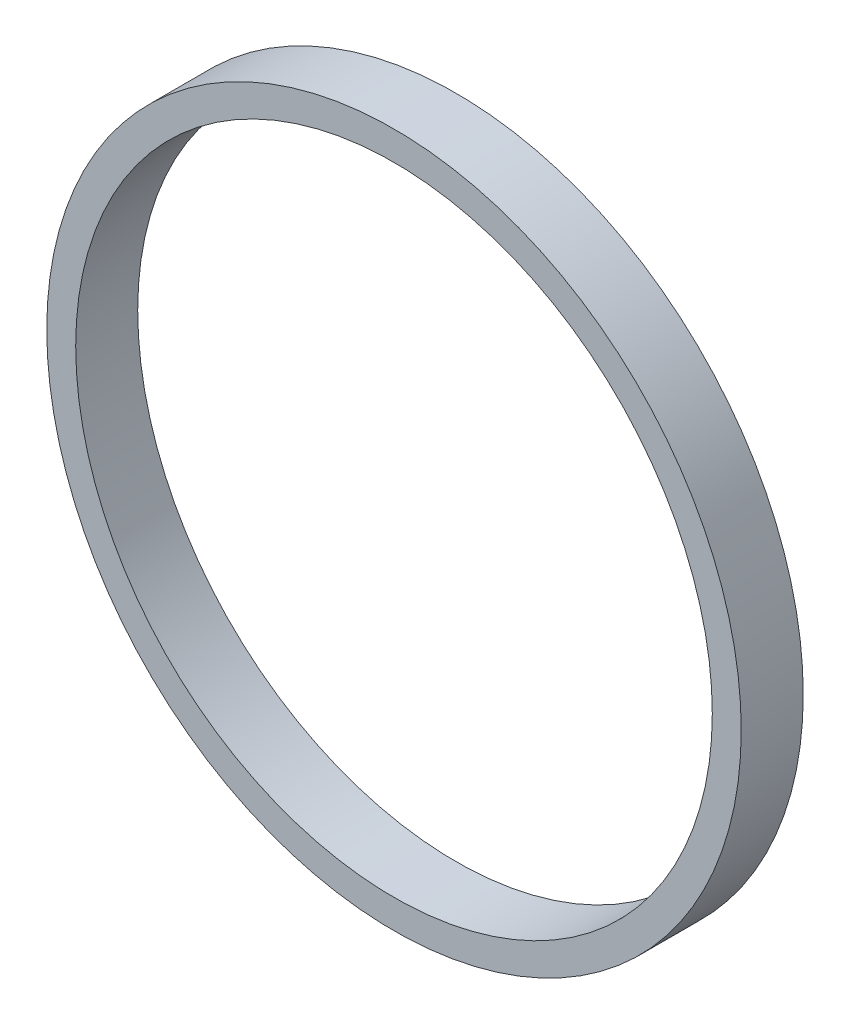
from build123d import *

# Parameters (mm, degrees)
SKETCH1_R           = 84
SKETCH1_R_2         = 77
BOSS_EXTRUDE1_DEPTH = 15


with BuildPart() as part:
    # Sketch1 → Boss-Extrude1 (new body)
    with BuildSketch(Plane.XY):
        Circle(SKETCH1_R)
        Circle(SKETCH1_R_2, mode=Mode.SUBTRACT)
    extrude(amount=BOSS_EXTRUDE1_DEPTH)


solid = part.part
